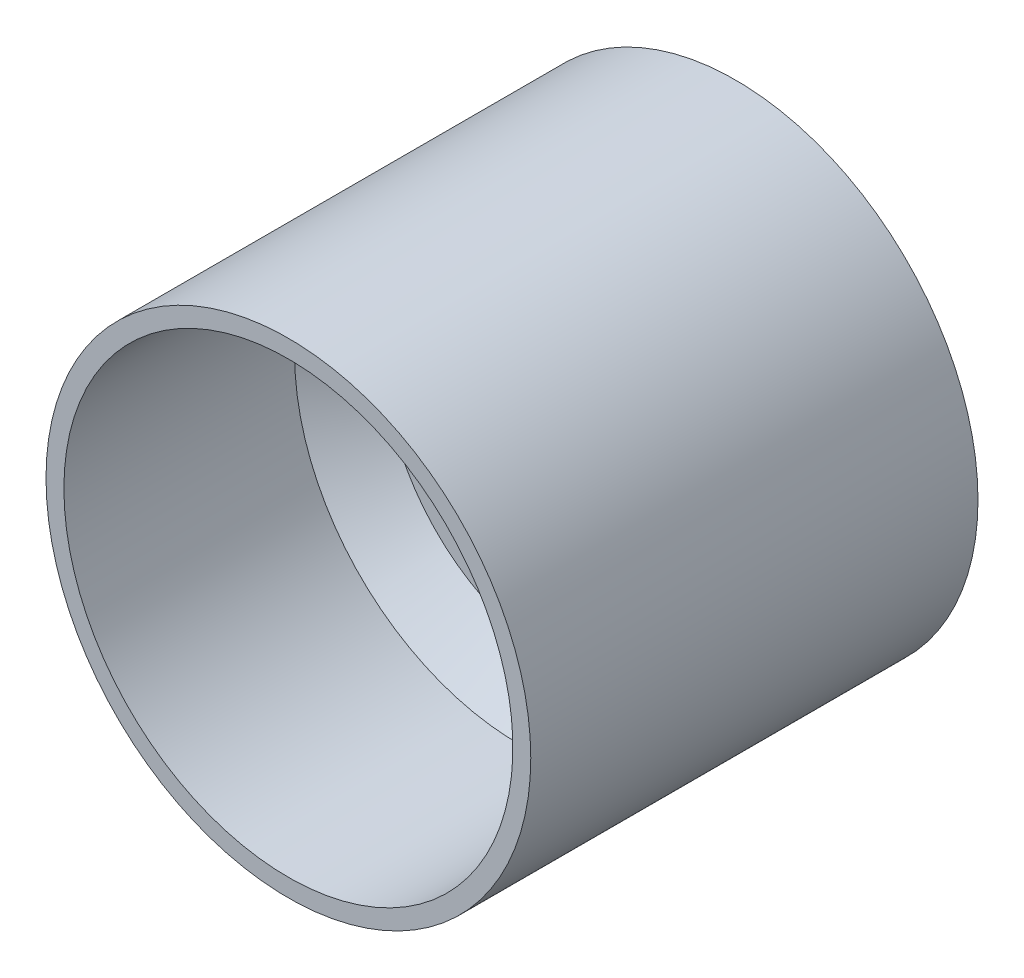
from build123d import *

# Parameters (mm, degrees)
SKETCH2_R          = 2
CUT_EXTRUDE1_DEPTH = 10
SKETCH3_W          = 25.1
SKETCH3_H          = 3
CHAMFER1_SIZE      = 5
SKETCH4_R          = 1.5
SKETCH4_R_2        = 1.55
SKETCH4_R_3        = 5.5
CUT_EXTRUDE2_DEPTH = 10


with BuildPart() as part:
    # Sketch1 → Revolve1 (revolve)
    with BuildSketch(Plane(origin=(0, 0, 0), x_dir=(1, 0, 0), z_dir=(0, 1, 0))):
        Polygon((15.25, 26.5), (15.25, 23.5), (25.1, 23.5), (25.1, -23.5), (27.1, -23.5), (27.1, 26.5), align=None)
    revolve(axis=Axis((0, 0, -51.288157895), (0, 0, 1)))

    # Sketch2 → Cut-Extrude1 (cut)
    with BuildSketch(Plane(origin=(0, 0, -26.5), x_dir=(-1, 0, 0), z_dir=(0, 0, -1))):
        with Locations((0, 20.25)):
            Circle(SKETCH2_R)
        with Locations((17.537014427, -10.125)):
            Circle(SKETCH2_R)
        with Locations((-17.537014427, -10.125)):
            Circle(SKETCH2_R)
    extrude(amount=-CUT_EXTRUDE1_DEPTH, mode=Mode.SUBTRACT)

    # Sketch3 → Revolve2 (revolve)
    with BuildSketch(Plane(origin=(0, 0, 0), x_dir=(1, 0, 0), z_dir=(0, 1, 0))):
        with Locations((12.55, 8.8)):
            Rectangle(SKETCH3_W, SKETCH3_H)
    revolve(axis=Axis((0, 0, -51.288157895), (0, 0, 1)))

    # Chamfer1
    chamfer1_edges = [part.edges().sort_by_distance(p)[0] for p in [
        (-25.1, 0, -7.3),
        (-25.1, 0, -10.3),
    ]]
    chamfer(chamfer1_edges, length=CHAMFER1_SIZE)

    # Sketch4 → Cut-Extrude2 (cut)
    with BuildSketch(Plane(origin=(0, 0, -10.3), x_dir=(-1, 0, 0), z_dir=(0, 0, -1))):
        with Locations((0, 12.5)):
            Circle(SKETCH4_R)
        with Locations((0, -12.5)):
            Circle(SKETCH4_R)
        with Locations((-8.5, 0)):
            Circle(SKETCH4_R_2)
        with Locations((8.5, 0)):
            Circle(SKETCH4_R_2)
        Circle(SKETCH4_R_3)
    extrude(amount=-CUT_EXTRUDE2_DEPTH, mode=Mode.SUBTRACT)


solid = part.part
